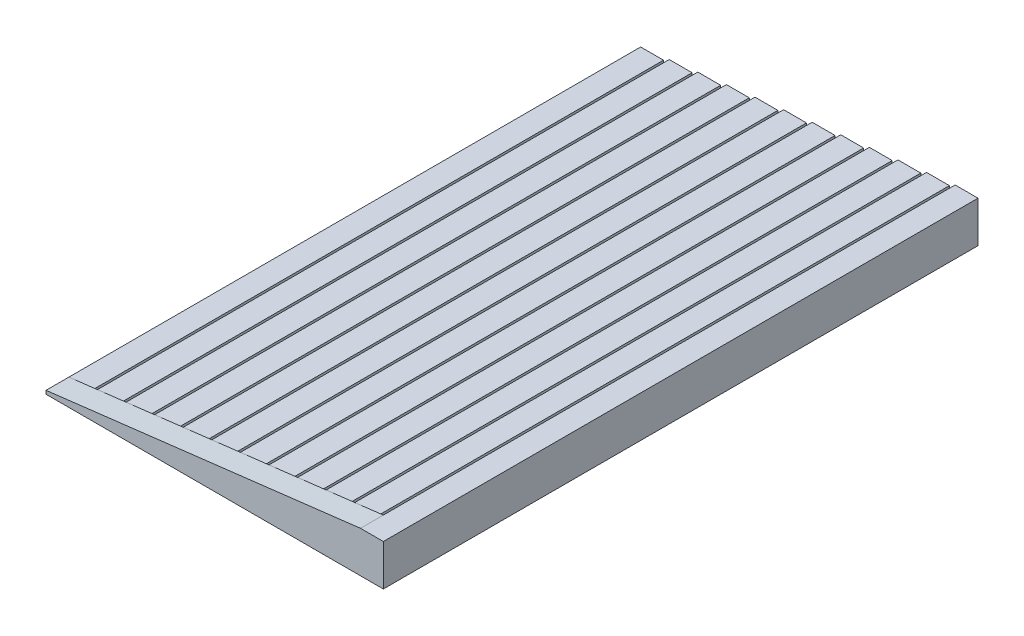
from build123d import *

# Parameters (mm, degrees)
SKETCH1_W              = 2
SKETCH1_H              = 0.3
BOSS_EXTRUDE1_DEPTH    = 50
SKETCH1_H_2            = 0.6
BOSS_EXTRUDE1_2_DEPTH  = 50
SKETCH1_H_3            = 0.9
BOSS_EXTRUDE1_3_DEPTH  = 50
SKETCH1_H_4            = 1.2
BOSS_EXTRUDE1_4_DEPTH  = 50
SKETCH1_H_5            = 1.5
BOSS_EXTRUDE1_5_DEPTH  = 50
SKETCH1_H_6            = 1.8
BOSS_EXTRUDE1_6_DEPTH  = 50
SKETCH1_H_7            = 2.1
BOSS_EXTRUDE1_7_DEPTH  = 50
SKETCH1_H_8            = 2.4
BOSS_EXTRUDE1_8_DEPTH  = 50
SKETCH1_H_9            = 2.7
BOSS_EXTRUDE1_9_DEPTH  = 50
SKETCH1_H_10           = 3
BOSS_EXTRUDE1_10_DEPTH = 50
SKETCH1_H_11           = 3.3
BOSS_EXTRUDE1_11_DEPTH = 50
SKETCH1_H_12           = 3.6
BOSS_EXTRUDE1_12_DEPTH = 50
BOSS_EXTRUDE2_DEPTH    = 2


with BuildPart() as part:
    # Sketch1 → Boss-Extrude1 (new body)
    with BuildSketch(Plane.XY):
        with Locations((1, 0.15)):
            Rectangle(SKETCH1_W, SKETCH1_H)
    extrude(amount=BOSS_EXTRUDE1_DEPTH)



with BuildPart() as body_2:
    # Sketch1 → Boss-Extrude1 2 (new body)
    with BuildSketch(Plane.XY):
        with Locations((3.5, 0.3)):
            Rectangle(SKETCH1_W, SKETCH1_H_2)
    extrude(amount=BOSS_EXTRUDE1_2_DEPTH)


with BuildPart() as body_3:
    # Sketch1 → Boss-Extrude1 3 (new body)
    with BuildSketch(Plane.XY):
        with Locations((6, 0.45)):
            Rectangle(SKETCH1_W, SKETCH1_H_3)
    extrude(amount=BOSS_EXTRUDE1_3_DEPTH)


with BuildPart() as body_4:
    # Sketch1 → Boss-Extrude1 4 (new body)
    with BuildSketch(Plane.XY):
        with Locations((8.5, 0.6)):
            Rectangle(SKETCH1_W, SKETCH1_H_4)
    extrude(amount=BOSS_EXTRUDE1_4_DEPTH)


with BuildPart() as body_5:
    # Sketch1 → Boss-Extrude1 5 (new body)
    with BuildSketch(Plane.XY):
        with Locations((11, 0.75)):
            Rectangle(SKETCH1_W, SKETCH1_H_5)
    extrude(amount=BOSS_EXTRUDE1_5_DEPTH)


with BuildPart() as body_6:
    # Sketch1 → Boss-Extrude1 6 (new body)
    with BuildSketch(Plane.XY):
        with Locations((13.5, 0.9)):
            Rectangle(SKETCH1_W, SKETCH1_H_6)
    extrude(amount=BOSS_EXTRUDE1_6_DEPTH)


with BuildPart() as body_7:
    # Sketch1 → Boss-Extrude1 7 (new body)
    with BuildSketch(Plane.XY):
        with Locations((16, 1.05)):
            Rectangle(SKETCH1_W, SKETCH1_H_7)
    extrude(amount=BOSS_EXTRUDE1_7_DEPTH)


with BuildPart() as body_8:
    # Sketch1 → Boss-Extrude1 8 (new body)
    with BuildSketch(Plane.XY):
        with Locations((18.5, 1.2)):
            Rectangle(SKETCH1_W, SKETCH1_H_8)
    extrude(amount=BOSS_EXTRUDE1_8_DEPTH)


with BuildPart() as body_9:
    # Sketch1 → Boss-Extrude1 9 (new body)
    with BuildSketch(Plane.XY):
        with Locations((21, 1.35)):
            Rectangle(SKETCH1_W, SKETCH1_H_9)
    extrude(amount=BOSS_EXTRUDE1_9_DEPTH)


with BuildPart() as body_10:
    # Sketch1 → Boss-Extrude1 10 (new body)
    with BuildSketch(Plane.XY):
        with Locations((23.5, 1.5)):
            Rectangle(SKETCH1_W, SKETCH1_H_10)
    extrude(amount=BOSS_EXTRUDE1_10_DEPTH)


with BuildPart() as body_11:
    # Sketch1 → Boss-Extrude1 11 (new body)
    with BuildSketch(Plane.XY):
        with Locations((26, 1.65)):
            Rectangle(SKETCH1_W, SKETCH1_H_11)
    extrude(amount=BOSS_EXTRUDE1_11_DEPTH)


with BuildPart() as body_12:
    # Sketch1 → Boss-Extrude1 12 (new body)
    with BuildSketch(Plane.XY):
        with Locations((28.5, 1.8)):
            Rectangle(SKETCH1_W, SKETCH1_H_12)
    extrude(amount=BOSS_EXTRUDE1_12_DEPTH)


with BuildPart() as part_1:
    add(part.part)

    add(body_2.part)  # Boss-Extrude2 merges body 2

    add(body_3.part)  # Boss-Extrude2 merges body 3

    add(body_4.part)  # Boss-Extrude2 merges body 4

    add(body_5.part)  # Boss-Extrude2 merges body 5

    add(body_6.part)  # Boss-Extrude2 merges body 6

    add(body_7.part)  # Boss-Extrude2 merges body 7

    add(body_8.part)  # Boss-Extrude2 merges body 8

    add(body_9.part)  # Boss-Extrude2 merges body 9

    add(body_10.part)  # Boss-Extrude2 merges body 10

    add(body_11.part)  # Boss-Extrude2 merges body 11

    add(body_12.part)  # Boss-Extrude2 merges body 12
    # Sketch2 → Boss-Extrude2 (add)
    with BuildSketch(Plane.XY.offset(50)):
        Polygon((0, 0), (29.5, 0), (29.5, 3.6), (27.5, 3.6), (0, 0.3), align=None)
    extrude(amount=BOSS_EXTRUDE2_DEPTH)


solid = part_1.part
